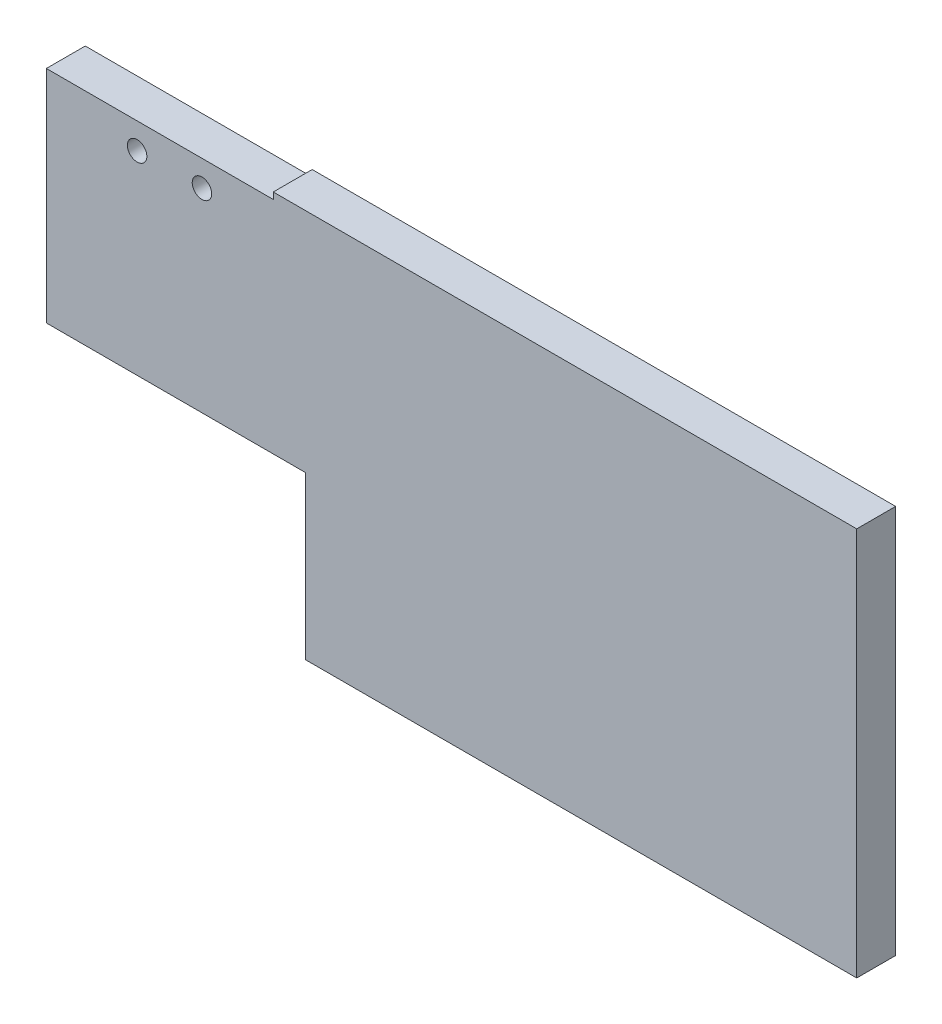
from build123d import *

# Parameters (mm, degrees)
ESQUISSE1_W             = 125
ESQUISSE1_H             = 60
ESQUISSE1_R             = 1.5
BOSS_EXTRU_1_DEPTH      = 6
ESQUISSE2_W             = 40
ESQUISSE2_H             = 25
ESQUISSE2_W_2           = 35
ESQUISSE2_H_2           = 1
ENL_V_MAT_EXTRU_1_DEPTH = 6


with BuildPart() as part:
    # Esquisse1 → Boss.-Extru.1 (new body)
    with BuildSketch(Plane.XY):
        with Locations((16.823229439, -0.568627451)):
            Rectangle(ESQUISSE1_W, ESQUISSE1_H)
        with Locations((-31.676770561, 24.431372549)):
            Circle(ESQUISSE1_R, mode=Mode.SUBTRACT)
        with Locations((-21.676770561, 24.431372549)):
            Circle(ESQUISSE1_R, mode=Mode.SUBTRACT)
    extrude(amount=BOSS_EXTRU_1_DEPTH)

    # Esquisse2 → Enlèv. mat.-Extru.1 (cut)
    with BuildSketch(Plane.XY.offset(6)):
        with Locations((-25.676770561, -18.068627451)):
            Rectangle(ESQUISSE2_W, ESQUISSE2_H)
        with Locations((-28.176770561, 28.931372549)):
            Rectangle(ESQUISSE2_W_2, ESQUISSE2_H_2)
    extrude(amount=-ENL_V_MAT_EXTRU_1_DEPTH, mode=Mode.SUBTRACT)


solid = part.part
